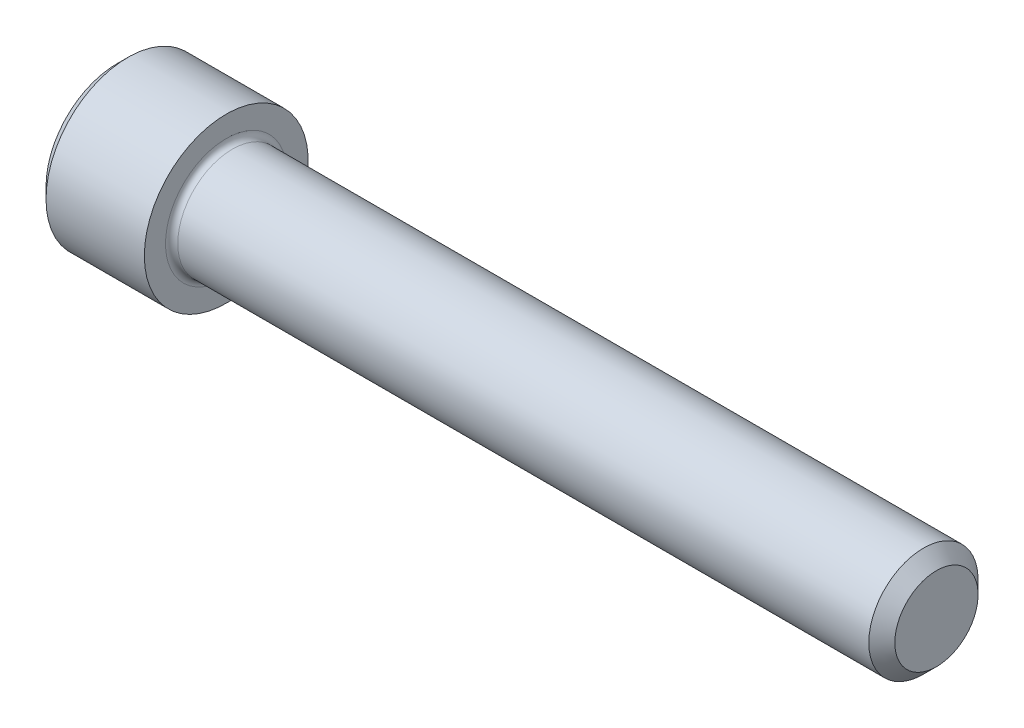
from build123d import *

# Parameters (mm, degrees)
FILLET1_R   = 0.3556
HEX_2_DEPTH = 3.048


with BuildPart() as part:
    # BodySke → Base-Revolve (revolve)
    with BuildSketch(Plane.XY):
        Polygon((0, 0), (0, 4.1275), (0.635, 4.7625), (6.35, 4.7625), (6.35, 3.175), (46.86935, 3.175), (47.625, 2.41935), (47.625, 0), align=None)
    revolve(axis=Axis((-31.75, 0, 0), (1, 0, 0)))

    # Fillet1
    fillet1_edges = [part.edges().sort_by_distance(p)[0] for p in [
        (6.35, -3.175, 0),
    ]]
    fillet(fillet1_edges, radius=FILLET1_R)

    # Sketch2 → Hex-PreBroach (revolve, cut)
    with BuildSketch(Plane.XY):
        Polygon((0, 2.38125), (3.048, 2.38125), (4.422815329, 0), (0, 0), align=None)
    revolve(axis=Axis((0, 0, 0), (1, 0, 0)), mode=Mode.SUBTRACT)

    # Sketch3 → Hex 2 (cut)
    with BuildSketch(Plane(origin=(0, 0, 0), x_dir=(0, 0.5, 0.866025404), z_dir=(-1, 0, 0))):
        Polygon((1.374815329, 2.38125), (-1.374815329, 2.38125), (-2.749630657, 0), (-1.374815329, -2.38125), (1.374815329, -2.38125), (2.749630657, 0), align=None)
    extrude(amount=-HEX_2_DEPTH, mode=Mode.SUBTRACT)


solid = part.part
